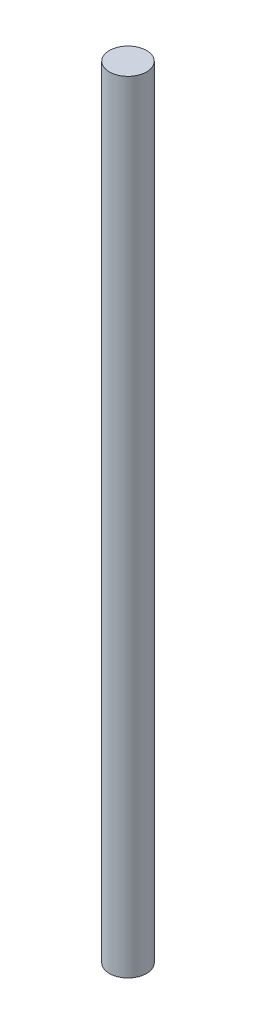
from build123d import *

# Parameters (mm, degrees)
SKETCH_1_R      = 2
EXTRUDE_1_DEPTH = 84


with BuildPart() as part:
    # 草图1 → 凸台-拉伸1 (new body)
    with BuildSketch(Plane(origin=(0, 0, 0), x_dir=(1, 0, 0), z_dir=(0, 1, 0))):
        Circle(SKETCH_1_R)
    extrude(amount=EXTRUDE_1_DEPTH)


solid = part.part
